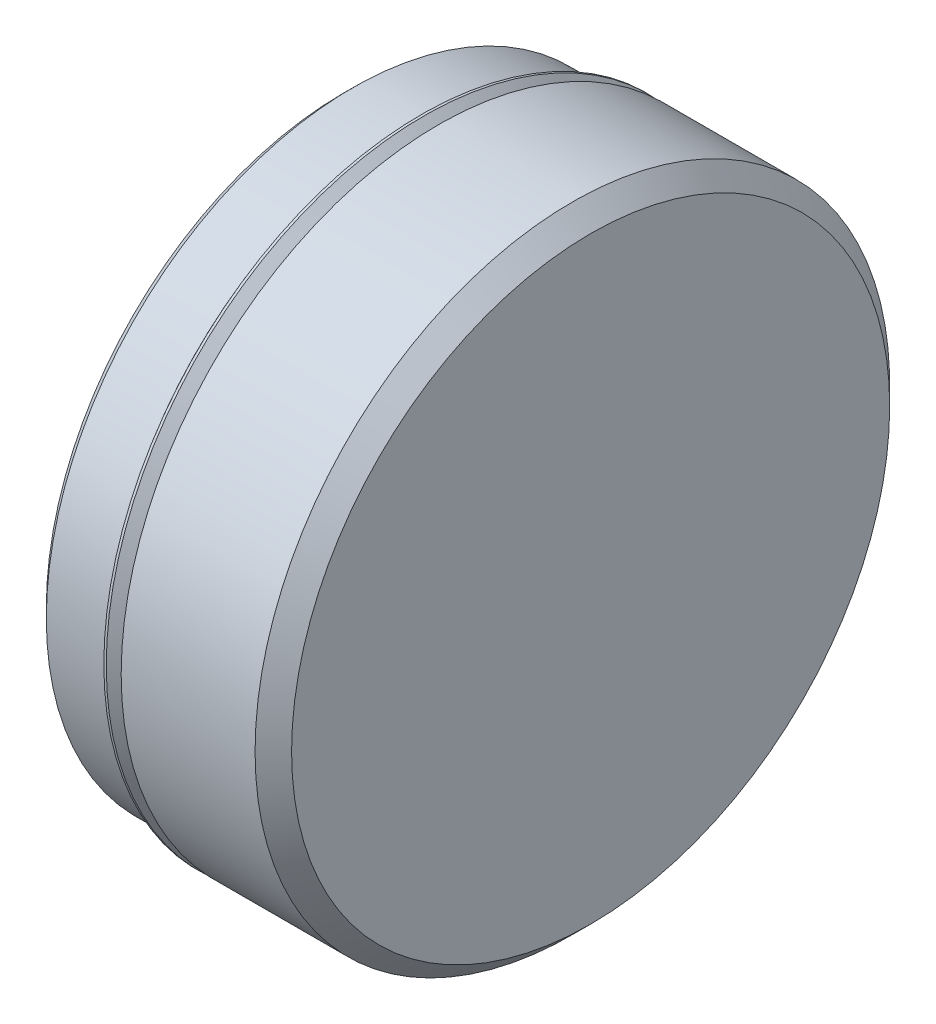
from build123d import *


with BuildPart() as part:
    # Sketch1 → Revolve1 (revolve)
    with BuildSketch(Plane.XY):
        Polygon((0, 0), (0, 24.80945), (0.762, 25.57145), (5.8166, 25.57145), (6.8707, 24.51735), (7.9248, 24.51735), (7.9248, 26.48585), (19.1008, 26.48585), (20.6248, 24.96185), (20.6248, 0), align=None)
    revolve(axis=Axis((20.6248, 0, 0), (-1, 0, 0)))

    # Sketch2 → Revolve2 (revolve)
    with BuildSketch(Plane.XY):
        with BuildLine():
            Line((6.477090712, 26.401681804), (7.789783697, 25.088988819))
            ThreePointArc((7.789783697, 25.088988819), (7.826981136, 24.999186258), (7.789783697, 24.909383697))
            Line((7.789783697, 24.909383697), (7.39775, 24.51735))
            Line((7.39775, 24.51735), (6.8707, 24.51735))
            Line((6.8707, 24.51735), (6.8707, 24.26335))
            Line((6.8707, 24.26335), (7.9248, 24.26335))
            Line((7.9248, 24.26335), (7.9248, 25.241340712))
            Line((7.9248, 25.241340712), (6.680290712, 26.48585))
            Line((6.680290712, 26.48585), (6.477090712, 26.48585))
            Line((6.477090712, 26.48585), (6.477090712, 26.401681804))
        make_face()
    revolve(axis=Axis((7.9248, 0, 0), (-1, 0, 0)))

    # Sketch3 → Cut-Revolve1 (revolve, cut)
    with BuildSketch(Plane.XY):
        Polygon((0, 0), (0, 20.5994), (0.762, 19.8374), (3.175, 19.8374), (3.175, 16.59255), (3.937, 15.83055), (12.7, 15.83055), (12.7, 0), align=None)
    revolve(axis=Axis((12.7, 0, 0), (-1, 0, 0)), mode=Mode.SUBTRACT)


solid = part.part
